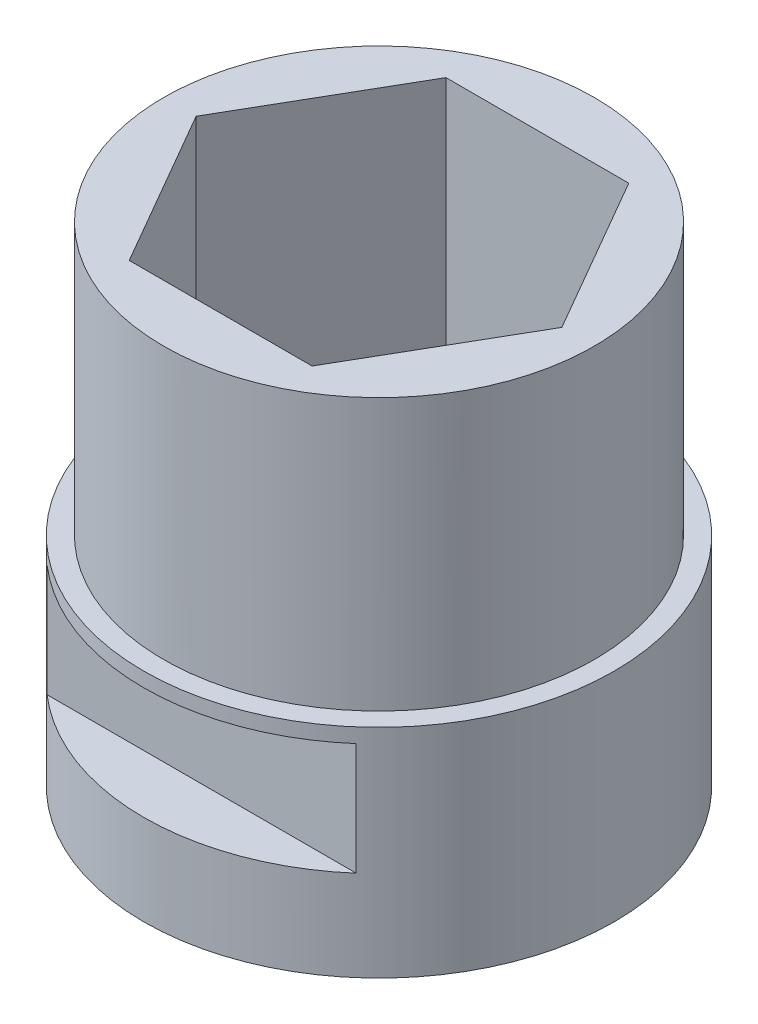
from build123d import *

# Parameters (mm, degrees)
SKETCH1_R               = 7.5565
BOSS_EXTRUDE1_DEPTH     = 16.51
SKETCH2_R               = 7.5565
SKETCH2_R_2             = 3.3
BOSS_EXTRUDE2_DEPTH     = 0.635
SKETCH4_R               = 8.255
SKETCH4_R_2             = 7.5565
BOSS_EXTRUDE3_DEPTH     = 7.62
SKETCH3_W               = 2.572814656
SKETCH3_H               = 3.937
SKETCH3_W_2             = 2.256055482
CUT_EXTRUDE1_DEPTH      = 9.255
CUT_EXTRUDE1_DEPTH_BACK = 9.255


with BuildPart() as part:
    # Sketch1 → Boss-Extrude1 (new body)
    with BuildSketch(Plane(origin=(0, 0, 0), x_dir=(1, 0, 0), z_dir=(0, 1, 0))):
        Circle(SKETCH1_R)
        Polygon((-3.207902433, 5.55625), (-6.415804866, 0), (-3.207902433, -5.55625), (3.207902433, -5.55625), (6.415804866, 0), (3.207902433, 5.55625), align=None, mode=Mode.SUBTRACT)
    extrude(amount=BOSS_EXTRUDE1_DEPTH)

    # Sketch2 → Boss-Extrude2 (add)
    with BuildSketch(Plane.XZ):
        Circle(SKETCH2_R)
        Circle(SKETCH2_R_2, mode=Mode.SUBTRACT)
    extrude(amount=BOSS_EXTRUDE2_DEPTH)

    # Sketch4 → Boss-Extrude3 (add)
    with BuildSketch(Plane.XZ.offset(0.635)):
        Circle(SKETCH4_R)
        Circle(SKETCH4_R_2, mode=Mode.SUBTRACT)
    extrude(amount=-BOSS_EXTRUDE3_DEPTH)

    # Sketch3 → Cut-Extrude1 (cut, two sides)
    with BuildSketch(Plane(origin=(0, 0, 0), x_dir=(0, 0, -1), z_dir=(1, 0, 0))) as cut_extrude1_sk:
        with Locations((-7.509407328, 4.5085)):
            Rectangle(SKETCH3_W, SKETCH3_H)
        with Locations((7.351027741, 4.5085)):
            Rectangle(SKETCH3_W_2, SKETCH3_H)
    extrude(amount=CUT_EXTRUDE1_DEPTH, mode=Mode.SUBTRACT)
    extrude(cut_extrude1_sk.sketch, amount=-CUT_EXTRUDE1_DEPTH_BACK, mode=Mode.SUBTRACT)


solid = part.part
